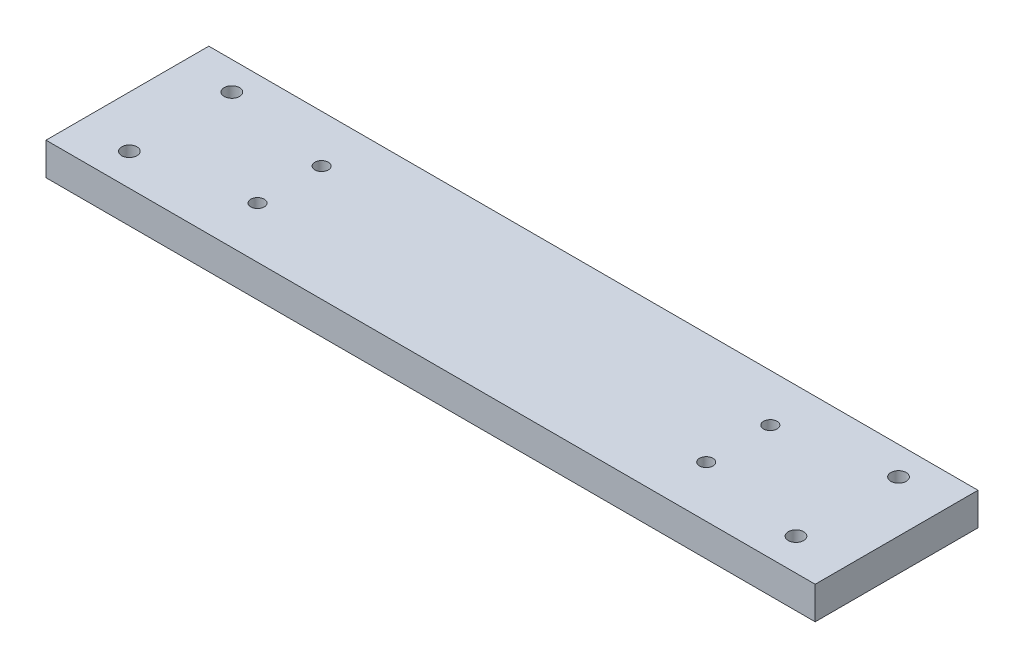
from build123d import *

# Parameters (mm, degrees)
SKETCH1_W           = 600
SKETCH1_H           = 127
BOSS_EXTRUDE1_DEPTH = 25.4
SKETCH2_R           = 6
CUT_EXTRUDE1_DEPTH  = 25.4
SKETCH3_R           = 5.25
CUT_EXTRUDE2_DEPTH  = 25.4


with BuildPart() as part:
    # Sketch1 → Boss-Extrude1 (new body)
    with BuildSketch(Plane(origin=(0, 0, 0), x_dir=(1, 0, 0), z_dir=(0, 1, 0))):
        with Locations((300, 63.5)):
            Rectangle(SKETCH1_W, SKETCH1_H)
    extrude(amount=BOSS_EXTRUDE1_DEPTH)

    # Sketch2 → Cut-Extrude1 (cut)
    with BuildSketch(Plane(origin=(0, 25.4, 0), x_dir=(1, 0, 0), z_dir=(0, 1, 0))):
        with Locations((40, 105)):
            Circle(SKETCH2_R)
        with Locations((40, 25)):
            Circle(SKETCH2_R)
        with Locations((560, 25)):
            Circle(SKETCH2_R)
        with Locations((560, 105)):
            Circle(SKETCH2_R)
    extrude(amount=-CUT_EXTRUDE1_DEPTH, mode=Mode.SUBTRACT)

    # Sketch3 → Cut-Extrude2 (cut)
    with BuildSketch(Plane(origin=(0, 25.4, 0), x_dir=(1, 0, 0), z_dir=(0, 1, 0))):
        with Locations((125, 90)):
            Circle(SKETCH3_R)
        with Locations((125, 40)):
            Circle(SKETCH3_R)
        with Locations((475, 40)):
            Circle(SKETCH3_R)
        with Locations((475, 90)):
            Circle(SKETCH3_R)
    extrude(amount=-CUT_EXTRUDE2_DEPTH, mode=Mode.SUBTRACT)


solid = part.part
